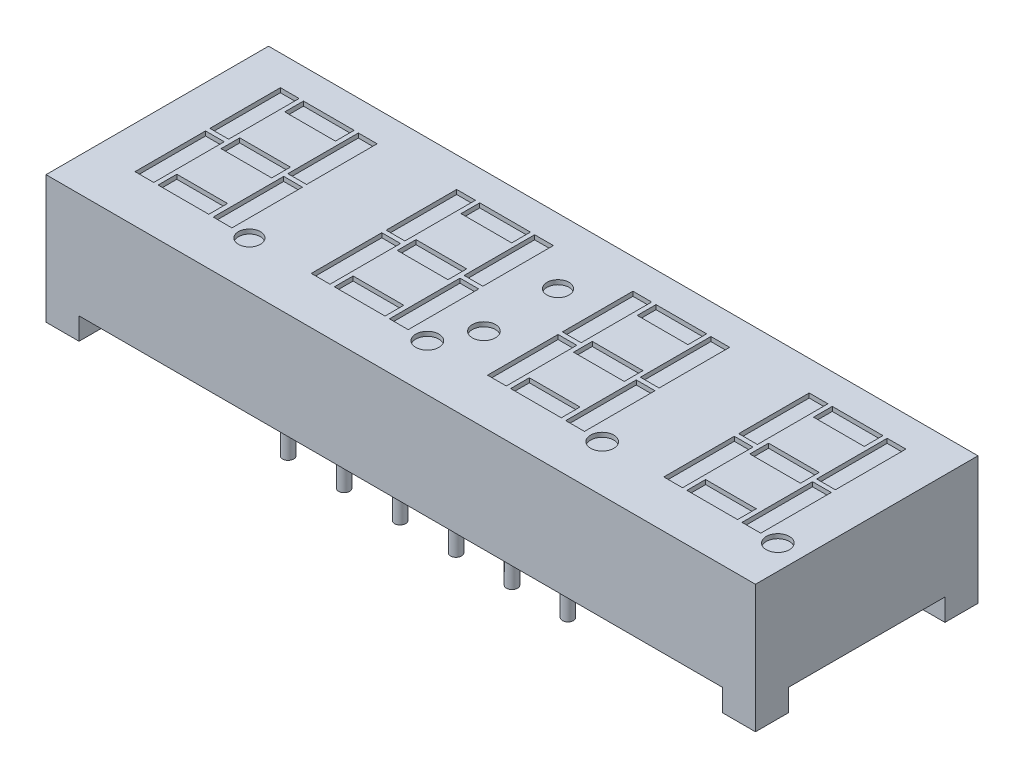
from build123d import *

# Parameters (mm, degrees)
SKETCH_1_W          = 32.2
SKETCH_1_H          = 10.1
EXTRUDE_1_DEPTH     = 5.8
CUT_EXTRUDE_1_DEPTH = 1
SKETCH_3_R          = 0.25
EXTRUDE_2_DEPTH     = 2
SKETCH_4_R          = 0.5
SKETCH_4_R_2        = 0.524489224
SKETCH_4_W          = 0.85
SKETCH_4_H          = 3.2
SKETCH_4_W_2        = 2.3
SKETCH_4_H_2        = 0.85
CUT_EXTRUDE_2_DEPTH = 0.2


with BuildPart() as part:
    # Эскиз1 → Бобышка-Вытянуть1 (new body)
    with BuildSketch(Plane(origin=(0, 0, 0), x_dir=(1, 0, 0), z_dir=(0, 1, 0))):
        Rectangle(SKETCH_1_W, SKETCH_1_H)
    extrude(amount=EXTRUDE_1_DEPTH)

    # Эскиз2 → Вырез-Вытянуть1 (cut)
    with BuildSketch(Plane.XZ):
        Polygon((-16.1, 3.55), (-14.6, 3.55), (-14.6, 5.05), (14.6, 5.05), (14.6, 3.55), (16.1, 3.55), (16.1, -3.55), (14.6, -3.55), (14.6, -5.05), (-14.6, -5.05), (-14.6, -3.55), (-16.1, -3.55), align=None)
    extrude(amount=-CUT_EXTRUDE_1_DEPTH, mode=Mode.SUBTRACT)

    # Эскиз3 → Бобышка-Вытянуть2 (add)
    with BuildSketch(Plane.XZ.offset(-1)):
        with Locations((-6.35, 3.81)):
            Circle(SKETCH_3_R)
        with Locations((-3.81, 3.81)):
            Circle(SKETCH_3_R)
        with Locations((-1.27, 3.81)):
            Circle(SKETCH_3_R)
        with Locations((1.27, 3.81)):
            Circle(SKETCH_3_R)
        with Locations((3.81, 3.81)):
            Circle(SKETCH_3_R)
        with Locations((6.35, 3.81)):
            Circle(SKETCH_3_R)
        with Locations((-3.81, -3.81)):
            Circle(SKETCH_3_R)
        with Locations((-1.27, -3.81)):
            Circle(SKETCH_3_R)
        with Locations((1.27, -3.81)):
            Circle(SKETCH_3_R)
        with Locations((3.81, -3.81)):
            Circle(SKETCH_3_R)
        with Locations((6.35, -3.81)):
            Circle(SKETCH_3_R)
        with Locations((-6.35, -3.81)):
            Circle(SKETCH_3_R)
    extrude(amount=EXTRUDE_2_DEPTH)

    # Эскиз4 → Вырез-Вытянуть2 (cut)
    with BuildSketch(Plane(origin=(0, 5.8, 0), x_dir=(1, 0, 0), z_dir=(0, 1, 0))):
        with Locations((0, 2.088518093)):
            Circle(SKETCH_4_R)
        with Locations((-8.994155163, -2.922635465)):
            Circle(SKETCH_4_R)
        with Locations((-0.009676216, -1.263887704)):
            Circle(SKETCH_4_R_2)
        with Locations((-0.919099914, -2.922635465)):
            Circle(SKETCH_4_R_2)
        with Locations((14.988407473, -2.922635465)):
            Circle(SKETCH_4_R_2)
        with Locations((7.017698273, -2.922635465)):
            Circle(SKETCH_4_R_2)
        with Locations((-13.773526097, -1.311481907)):
            Rectangle(SKETCH_4_W, SKETCH_4_H)
        with Locations((-12, 3.260742105)):
            Rectangle(SKETCH_4_W_2, SKETCH_4_H_2)
        with Locations((-13.775, 2.088518093)):
            Rectangle(SKETCH_4_W, SKETCH_4_H)
        with Locations((-10.225, 2.077364535)):
            Rectangle(SKETCH_4_W, SKETCH_4_H)
        with Locations((-10.213082834, -1.322635465)):
            Rectangle(SKETCH_4_W, SKETCH_4_H)
        with Locations((-12, 0.368523253)):
            Rectangle(SKETCH_4_W_2, SKETCH_4_H_2)
        with Locations((-11.998526097, -2.488527153)):
            Rectangle(SKETCH_4_W_2, SKETCH_4_H_2)
        with Locations((-5.773526097, -1.311481907)):
            Rectangle(SKETCH_4_W, SKETCH_4_H)
        with Locations((-4, 3.260742105)):
            Rectangle(SKETCH_4_W_2, SKETCH_4_H_2)
        with Locations((-5.775, 2.088518093)):
            Rectangle(SKETCH_4_W, SKETCH_4_H)
        with Locations((-2.225, 2.077364535)):
            Rectangle(SKETCH_4_W, SKETCH_4_H)
        with Locations((-2.213082834, -1.322635465)):
            Rectangle(SKETCH_4_W, SKETCH_4_H)
        with Locations((-4, 0.368523253)):
            Rectangle(SKETCH_4_W_2, SKETCH_4_H_2)
        with Locations((-3.998526097, -2.488527153)):
            Rectangle(SKETCH_4_W_2, SKETCH_4_H_2)
        with Locations((2.226473903, -1.311481907)):
            Rectangle(SKETCH_4_W, SKETCH_4_H)
        with Locations((4, 3.260742105)):
            Rectangle(SKETCH_4_W_2, SKETCH_4_H_2)
        with Locations((2.225, 2.088518093)):
            Rectangle(SKETCH_4_W, SKETCH_4_H)
        with Locations((5.775, 2.077364535)):
            Rectangle(SKETCH_4_W, SKETCH_4_H)
        with Locations((5.786917166, -1.322635465)):
            Rectangle(SKETCH_4_W, SKETCH_4_H)
        with Locations((4, 0.368523253)):
            Rectangle(SKETCH_4_W_2, SKETCH_4_H_2)
        with Locations((4.001473903, -2.488527153)):
            Rectangle(SKETCH_4_W_2, SKETCH_4_H_2)
        with Locations((10.226473903, -1.311481907)):
            Rectangle(SKETCH_4_W, SKETCH_4_H)
        with Locations((12, 3.260742105)):
            Rectangle(SKETCH_4_W_2, SKETCH_4_H_2)
        with Locations((10.225, 2.088518093)):
            Rectangle(SKETCH_4_W, SKETCH_4_H)
        with Locations((13.775, 2.077364535)):
            Rectangle(SKETCH_4_W, SKETCH_4_H)
        with Locations((13.786917166, -1.322635465)):
            Rectangle(SKETCH_4_W, SKETCH_4_H)
        with Locations((12, 0.368523253)):
            Rectangle(SKETCH_4_W_2, SKETCH_4_H_2)
        with Locations((12.001473903, -2.488527153)):
            Rectangle(SKETCH_4_W_2, SKETCH_4_H_2)
    extrude(amount=-CUT_EXTRUDE_2_DEPTH, mode=Mode.SUBTRACT)


solid = part.part
